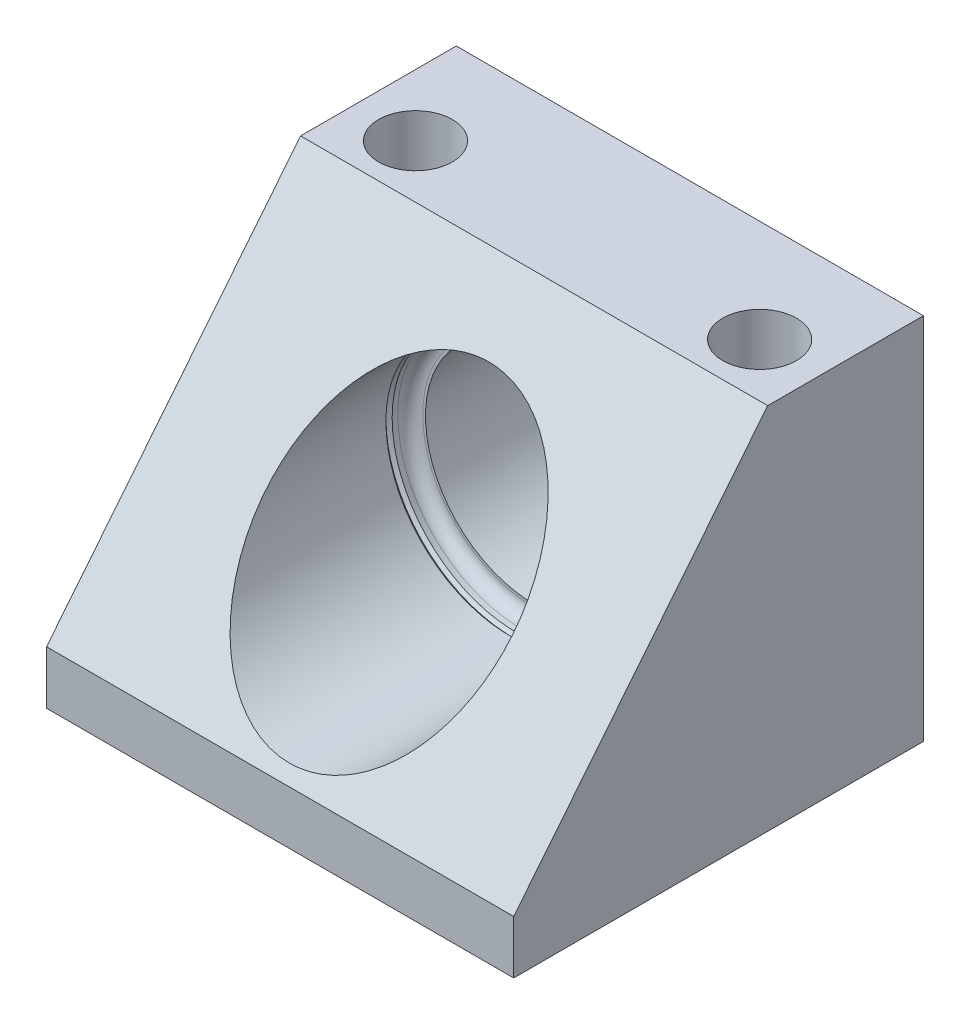
from build123d import *

# Parameters (mm, degrees)
SKETCH1_W          = 56.9976
SKETCH1_H          = 44.9834
SKETCH1_R          = 13.259
EXTRUDE1_DEPTH     = 49.9872
CUT_EXTRUDE1_DEPTH = 57.9976
SKETCH3_R          = 15.113
CUT_EXTRUDE2_DEPTH = 30.988
FILLET1_R          = 1.524
HOLE1_D            = 8.9916
HOLE1_DEPTH        = 44.9834


with BuildPart() as part:
    # Sketch1 → Extrude1 (new body)
    with BuildSketch(Plane.XY):
        with Locations((28.4988, 22.4917)):
            Rectangle(SKETCH1_W, SKETCH1_H)
        with Locations((28.4988, 23.0124)):
            Circle(SKETCH1_R, mode=Mode.SUBTRACT)
    extrude(amount=-EXTRUDE1_DEPTH)

    # Sketch2 → Cut-Extrude1 (cut, through all)
    with BuildSketch(Plane(origin=(56.9976, 0, 0), x_dir=(0, 0, -1), z_dir=(1, 0, 0))):
        Polygon((0, 44.9834), (30.988, 44.9834), (0, 6.5024), align=None)
    extrude(amount=-CUT_EXTRUDE1_DEPTH, mode=Mode.SUBTRACT)

    # Sketch3 → Cut-Extrude2 (cut)
    with BuildSketch(Plane(origin=(0, 0, 0), x_dir=(-1, 0, 0), z_dir=(0, 0, -1))):
        with Locations(Location((-28.4988, 23.0124, 0), (0, 0, 180))):  # turned: the seam where the file's is
            Circle(SKETCH3_R)
    extrude(amount=CUT_EXTRUDE2_DEPTH, mode=Mode.SUBTRACT)

    # Fillet1
    fillet1_edges = [part.edges().sort_by_distance(p)[0] for p in [
        (13.3858, 23.0124, -30.988),
    ]]
    fillet(fillet1_edges, radius=FILLET1_R)

    # Hole1
    with Locations(Plane(origin=(0, 44.9834, 0), x_dir=(-1, 0, 0), z_dir=(0, 1, 0))):
        with Locations((-7.5184, -37.4904), (-49.5046, -37.4904)):
            Hole(HOLE1_D / 2, depth=HOLE1_DEPTH)

    # Sketch6 → Cut-Revolve1 (revolve, cut)
    with BuildSketch(Plane(origin=(0, 23.0124, 0), x_dir=(-1, 0, 0), z_dir=(0, 1, 0)), mode=Mode.PRIVATE) as cut_revolve1_sk:
        Polygon((-13.3858, -28.0162), (-13.3858, -28.7782), (-13.0048, -28.3972), align=None)
        Polygon((-15.2398, -48.8952), (-15.2398, -49.9872), (-14.1478, -49.9872), align=None)
    revolve(cut_revolve1_sk.sketch.rotate(Axis((28.4988, 23.0124, 17.508123997), (0, 0, -1)), 180), axis=Axis((28.4988, 23.0124, 17.508123997), (0, 0, -1)), mode=Mode.SUBTRACT)  # turned: the seam where the file's is


solid = part.part
